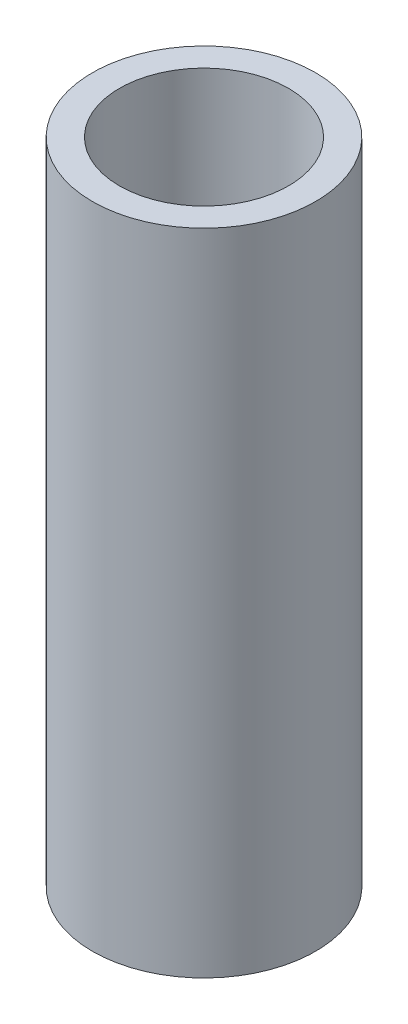
from build123d import *

# Parameters (mm, degrees)
SKETCH1_R           = 13.096875
SKETCH1_R_2         = 9.921875
BOSS_EXTRUDE1_DEPTH = 76.2


with BuildPart() as part:
    # Sketch1 → Boss-Extrude1 (new body)
    with BuildSketch(Plane(origin=(0, 0, 0), x_dir=(1, 0, 0), z_dir=(0, 1, 0))):
        Circle(SKETCH1_R)
        Circle(SKETCH1_R_2, mode=Mode.SUBTRACT)
    extrude(amount=BOSS_EXTRUDE1_DEPTH)


solid = part.part
